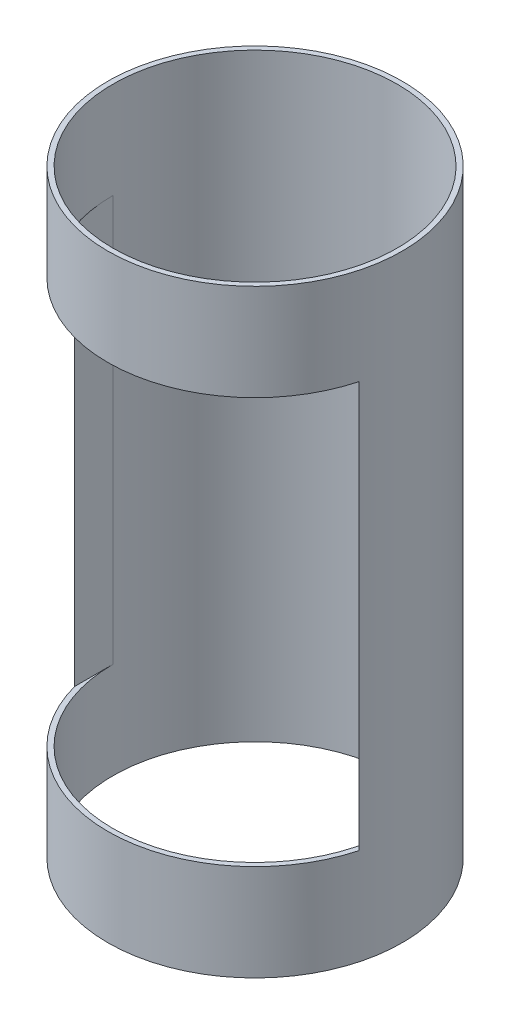
from build123d import *

# Parameters (mm, degrees)
SKETCH1_R           = 92.075
SKETCH1_R_2         = 88.9
BOSS_EXTRUDE1_DEPTH = 374.65
SKETCH2_W           = 177.8
SKETCH2_H           = 254
CUT_EXTRUDE1_DEPTH  = 93.075


with BuildPart() as part:
    # Sketch1 → Boss-Extrude1 (new body)
    with BuildSketch(Plane(origin=(0, 0, 0), x_dir=(1, 0, 0), z_dir=(0, 1, 0))):
        Circle(SKETCH1_R)
        Circle(SKETCH1_R_2, mode=Mode.SUBTRACT)
    extrude(amount=BOSS_EXTRUDE1_DEPTH)

    # Sketch2 → Cut-Extrude1 (cut, through all)
    with BuildSketch(Plane.XY):
        with Locations((0, 187.325)):
            Rectangle(SKETCH2_W, SKETCH2_H)
    extrude(amount=CUT_EXTRUDE1_DEPTH, mode=Mode.SUBTRACT)


solid = part.part
